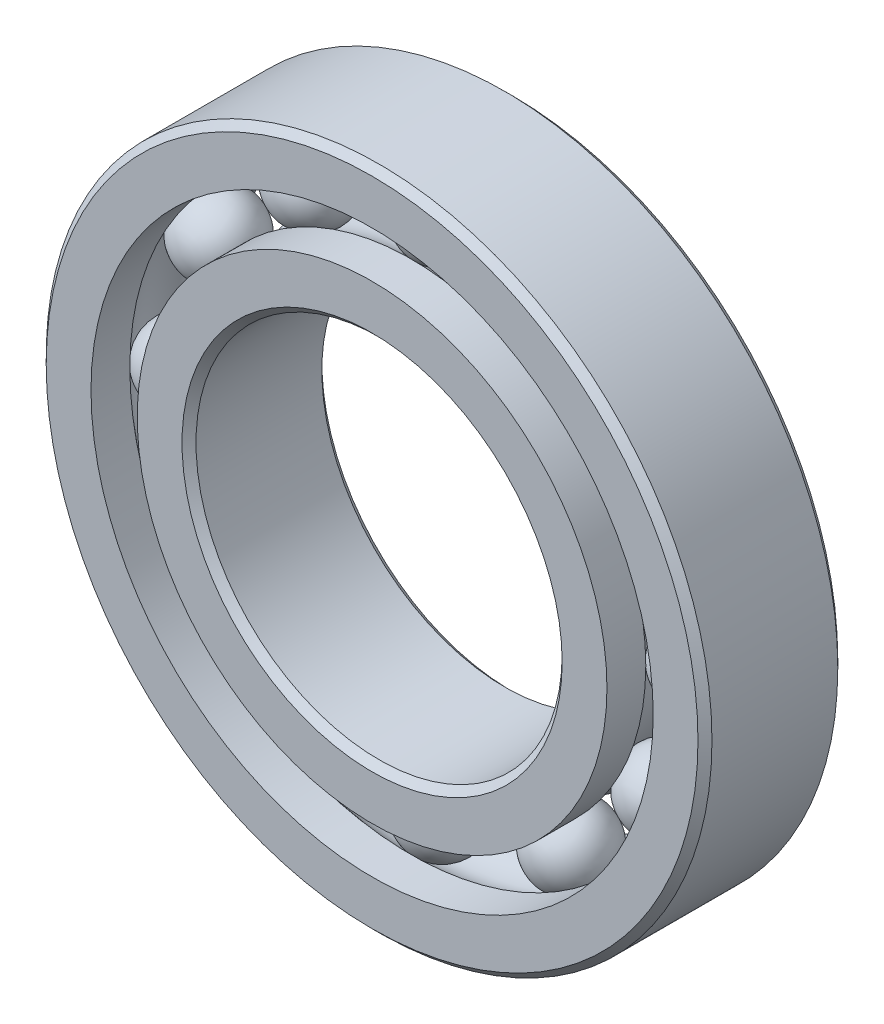
from build123d import *

# Parameters (mm, degrees)
CIRPATTERN1_COUNT = 12


with BuildPart() as part:
    # Sketch1 → Revolve1 (revolve)
    with BuildSketch(Plane(origin=(0, 0, 0), x_dir=(0, 0, -1), z_dir=(1, 0, 0))):
        with BuildLine():
            Line((9.45, 50), (-9.45, 50))
            Line((-9.45, 50), (-10.5, 48.95))
            Line((-10.5, 48.95), (-10.5, 42.222527473))
            Line((-10.5, 42.222527473), (-4.666666667, 42.222527473))
            ThreePointArc((-4.666666667, 42.222527473), (0, 44.566891337), (4.666666667, 42.222527473))
            Line((4.666666667, 42.222527473), (10.5, 42.222527473))
            Line((10.5, 42.222527473), (10.5, 48.95))
            Line((10.5, 48.95), (9.45, 50))
        make_face()
    revolve(axis=Axis((0, 0, 10.5), (0, 0, -1)))


with BuildPart() as body_2:
    # Sketch3 → Revolve3 (revolve)
    with BuildSketch(Plane(origin=(0, 0, 0), x_dir=(0, 0, -1), z_dir=(1, 0, 0))):
        with BuildLine():
            Line((-10.5, 35.277472527), (-4.666666667, 35.277472527))
            ThreePointArc((-4.666666667, 35.277472527), (0, 32.933108663), (4.666666667, 35.277472527))
            Line((4.666666667, 35.277472527), (10.5, 35.277472527))
            Line((10.5, 35.277472527), (10.5, 28.55))
            Line((10.5, 28.55), (9.45, 27.5))
            Line((9.45, 27.5), (-9.45, 27.5))
            Line((-9.45, 27.5), (-10.5, 28.55))
            Line((-10.5, 28.55), (-10.5, 35.277472527))
        make_face()
    revolve(axis=Axis((0, 0, 10.5), (0, 0, -1)))


with BuildPart() as body_3:
    # Sketch4 → Revolve4 (revolve)
    with BuildSketch(Plane(origin=(0, 0, 0), x_dir=(0, 0, -1), z_dir=(1, 0, 0))):
        with BuildLine():
            Line((-5.816891337, 38.75), (5.816891337, 38.75))
            ThreePointArc((5.816891337, 38.75), (0, 44.566891337), (-5.816891337, 38.75))
        make_face()
    revolve(axis=Axis((0, 38.75, 5.816891337), (0, 0, -1)))


with BuildPart() as cirpattern1_1:
    # CirPattern1: pattern copy
    add(body_3.part.rotate(Axis((0, 0, -10.5), (0, 0, 1)), 1 * 360 / CIRPATTERN1_COUNT))


with BuildPart() as cirpattern1_2:
    # CirPattern1: pattern copy
    add(body_3.part.rotate(Axis((0, 0, -10.5), (0, 0, 1)), 2 * 360 / CIRPATTERN1_COUNT))


with BuildPart() as cirpattern1_3:
    # CirPattern1: pattern copy
    add(body_3.part.rotate(Axis((0, 0, -10.5), (0, 0, 1)), 3 * 360 / CIRPATTERN1_COUNT))


with BuildPart() as cirpattern1_4:
    # CirPattern1: pattern copy
    add(body_3.part.rotate(Axis((0, 0, -10.5), (0, 0, 1)), 4 * 360 / CIRPATTERN1_COUNT))


with BuildPart() as cirpattern1_5:
    # CirPattern1: pattern copy
    add(body_3.part.rotate(Axis((0, 0, -10.5), (0, 0, 1)), 5 * 360 / CIRPATTERN1_COUNT))


with BuildPart() as cirpattern1_6:
    # CirPattern1: pattern copy
    add(body_3.part.rotate(Axis((0, 0, -10.5), (0, 0, 1)), 6 * 360 / CIRPATTERN1_COUNT))


with BuildPart() as cirpattern1_7:
    # CirPattern1: pattern copy
    add(body_3.part.rotate(Axis((0, 0, -10.5), (0, 0, 1)), 7 * 360 / CIRPATTERN1_COUNT))


with BuildPart() as cirpattern1_8:
    # CirPattern1: pattern copy
    add(body_3.part.rotate(Axis((0, 0, -10.5), (0, 0, 1)), 8 * 360 / CIRPATTERN1_COUNT))


with BuildPart() as cirpattern1_9:
    # CirPattern1: pattern copy
    add(body_3.part.rotate(Axis((0, 0, -10.5), (0, 0, 1)), 9 * 360 / CIRPATTERN1_COUNT))


with BuildPart() as cirpattern1_10:
    # CirPattern1: pattern copy
    add(body_3.part.rotate(Axis((0, 0, -10.5), (0, 0, 1)), 10 * 360 / CIRPATTERN1_COUNT))


with BuildPart() as cirpattern1_11:
    # CirPattern1: pattern copy
    add(body_3.part.rotate(Axis((0, 0, -10.5), (0, 0, 1)), 11 * 360 / CIRPATTERN1_COUNT))


solid = Compound([part.part, body_2.part, body_3.part, cirpattern1_1.part, cirpattern1_2.part, cirpattern1_3.part, cirpattern1_4.part, cirpattern1_5.part, cirpattern1_6.part, cirpattern1_7.part, cirpattern1_8.part, cirpattern1_9.part, cirpattern1_10.part, cirpattern1_11.part])
